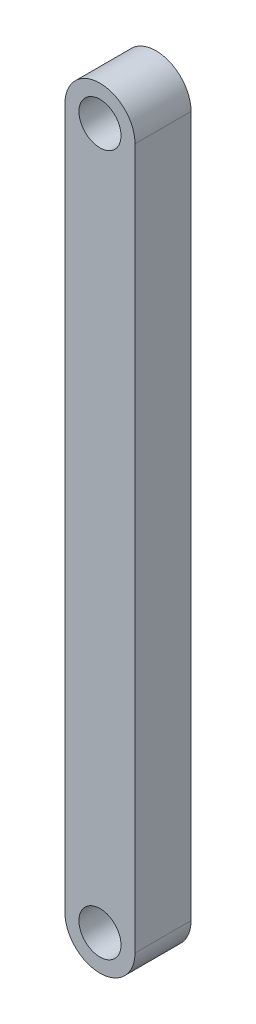
from build123d import *

# Parameters (mm, degrees)
SKETCH1_R           = 7.5
BOSS_EXTRUDE1_DEPTH = 20


with BuildPart() as part:
    # Sketch1 → Boss-Extrude1 (new body)
    with BuildSketch(Plane.XY):
        with BuildLine():
            Line((-12.5, -125), (-12.5, 125))
            ThreePointArc((-12.5, 125), (0, 137.5), (12.5, 125))
            Line((12.5, 125), (12.5, -125))
            ThreePointArc((12.5, -125), (0, -137.5), (-12.5, -125))
        make_face()
        with Locations((0, 125)):
            Circle(SKETCH1_R, mode=Mode.SUBTRACT)
        with Locations((0, -125)):
            Circle(SKETCH1_R, mode=Mode.SUBTRACT)
    extrude(amount=BOSS_EXTRUDE1_DEPTH)


solid = part.part
